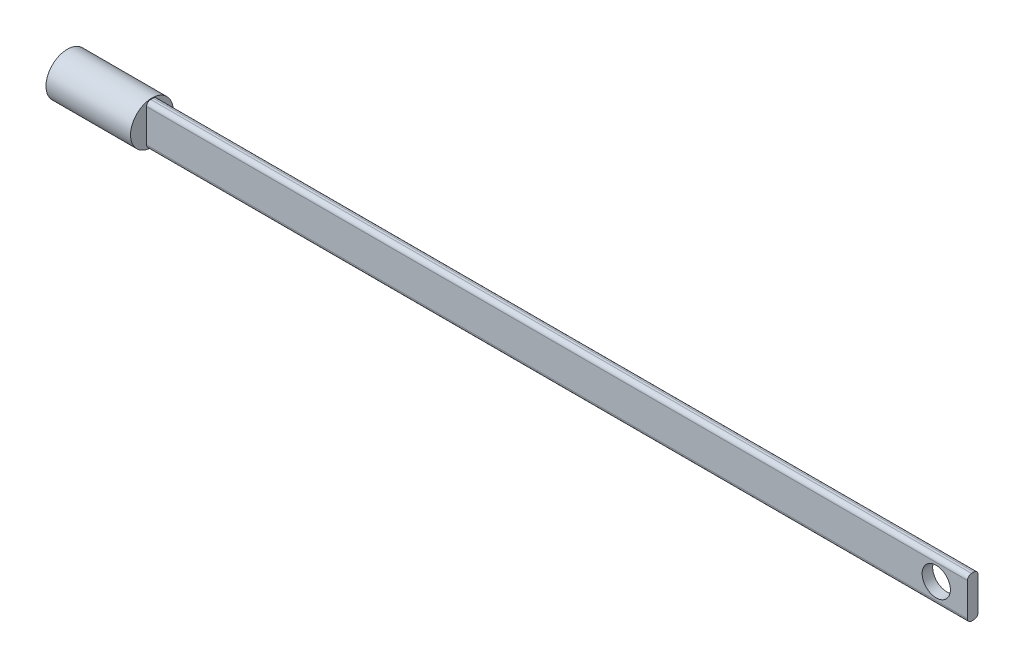
from build123d import *

# Parameters (mm, degrees)
SKETCH1_R           = 6.604
BOSS_EXTRUDE1_DEPTH = 26.162
SKETCH2_R           = 4.602953069
CUT_EXTRUDE1_DEPTH  = 11.684
SKETCH3_W           = 3.260632866
SKETCH3_H           = 12.799200652
BOSS_EXTRUDE2_DEPTH = 254
FILLET2_R           = 1.27
CUT_EXTRUDE4_REACH  = 10.234
SKETCH9_R           = 4.3688


with BuildPart() as part:
    # Sketch1 → Boss-Extrude1 (new body)
    with BuildSketch(Plane(origin=(0, 0, 0), x_dir=(0, 0, -1), z_dir=(1, 0, 0))):
        Circle(SKETCH1_R)
    extrude(amount=BOSS_EXTRUDE1_DEPTH)

    # Sketch2 → Cut-Extrude1 (cut)
    with BuildSketch(Plane.ZY):
        Circle(SKETCH2_R)
    extrude(amount=-CUT_EXTRUDE1_DEPTH, mode=Mode.SUBTRACT)

    # Sketch3 → Boss-Extrude2 (add)
    with BuildSketch(Plane(origin=(26.162, 0, 0), x_dir=(0, 0, -1), z_dir=(1, 0, 0))):
        Rectangle(SKETCH3_W, SKETCH3_H)
    extrude(amount=BOSS_EXTRUDE2_DEPTH)

    # Fillet2
    fillet2_edges = [part.edges().sort_by_distance(p)[0] for p in [
        (153.162, -6.399600326, -1.630316433),
        (153.162, 6.399600326, -1.630316433),
        (153.162, 6.399600326, 1.630316433),
        (153.162, -6.399600326, 1.630316433),
    ]]
    fillet(fillet2_edges, radius=FILLET2_R)

    # Sketch9 → Cut-Extrude4 (cut, up to next)
    with BuildSketch(Plane.XY.offset(1.630316433), mode=Mode.PRIVATE) as cut_extrude4_sk1:
        with Locations((270.502993622, 0)):
            Circle(SKETCH9_R)
    cut_extrude4_tool1 = extrude(cut_extrude4_sk1.sketch, amount=-CUT_EXTRUDE4_REACH, mode=Mode.PRIVATE) & part.part
    add(cut_extrude4_tool1.solids().sort_by_distance((270.502994, 0, 1.630316))[0], mode=Mode.SUBTRACT)


solid = part.part
